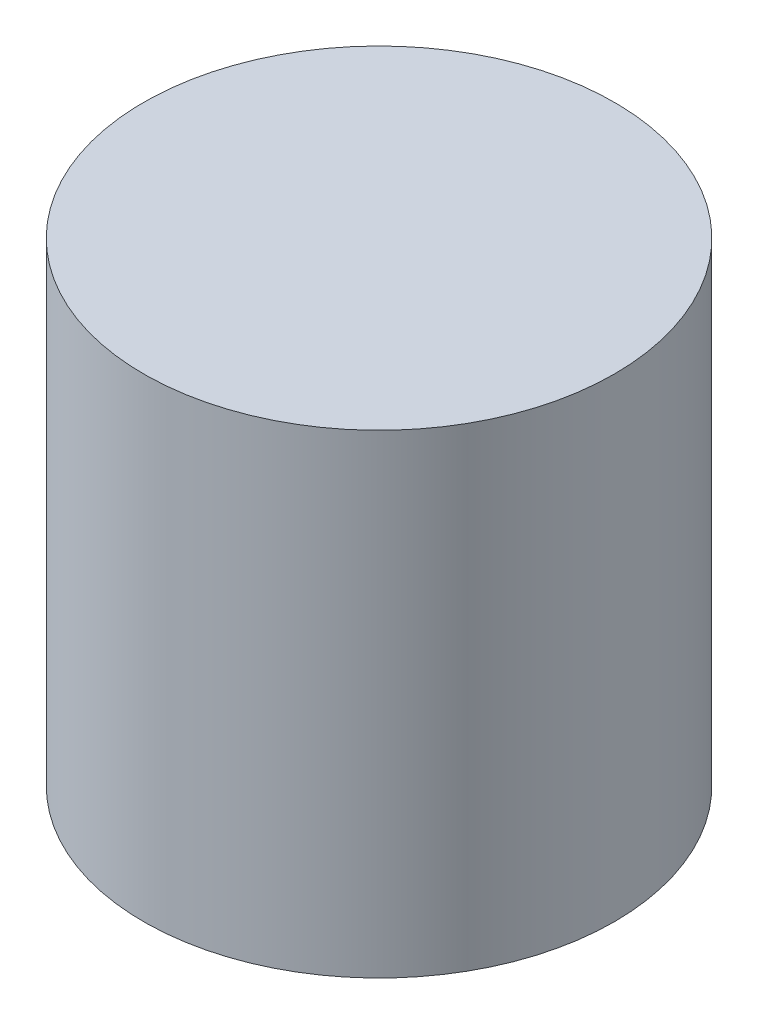
from build123d import *

# Parameters (mm, degrees)
SKETCH1_R                = 12.7
BOSS_EXTRUDE1_DEPTH      = 8.8
BOSS_EXTRUDE1_DEPTH_BACK = 16.8


with BuildPart() as part:
    # Sketch1 → Boss-Extrude1 (new body, two sides)
    with BuildSketch(Plane(origin=(0, 0, 0), x_dir=(1, 0, 0), z_dir=(0, 1, 0))) as boss_extrude1_sk:
        Circle(SKETCH1_R)
    extrude(amount=BOSS_EXTRUDE1_DEPTH)
    extrude(boss_extrude1_sk.sketch, amount=-BOSS_EXTRUDE1_DEPTH_BACK)


solid = part.part
